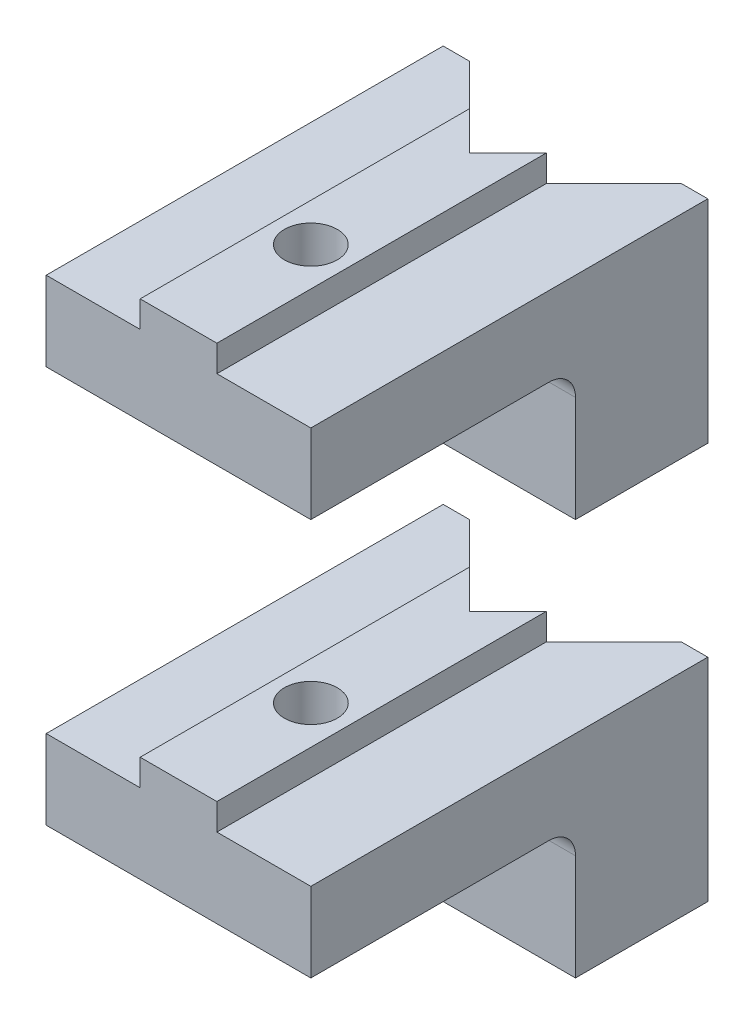
from build123d import *

# Parameters (mm, degrees)
MAIN_DEPTH          = 15
ESQUISSE2_R         = 1
TOPHOLE_DEPTH       = 17.30950643
CUT_EXTRUDE1_DEPTH  = 17.30950643
BOSS_EXTRUDE1_DEPTH = 5
FILLET1_R           = 1
LPATTERN1_COUNT     = 2
LPATTERN1_PITCH     = 15


with BuildPart() as part:
    # Esquisse1 → Main (new body)
    with BuildSketch(Plane.XY):
        Polygon((-5, 0), (-5, 3), (-1.45, 3), (-1.45, 4), (1.45, 4), (1.45, 3), (5, 3), (5, 0), align=None)
    extrude(amount=MAIN_DEPTH)

    # Esquisse2 → TopHole (cut, through all)
    with BuildSketch(Plane(origin=(0, 4, 0), x_dir=(1, 0, 0), z_dir=(0, 1, 0))):
        with Locations((0, -10)):
            Circle(ESQUISSE2_R)
    extrude(amount=-TOPHOLE_DEPTH, mode=Mode.SUBTRACT)

    # Sketch1 → Cut-Extrude1 (cut, through all)
    with BuildSketch(Plane(origin=(0, 0, 0), x_dir=(-1, 0, 0), z_dir=(0, -1, 0))):
        Polygon((5, 1), (0, -4), (-5, 1), align=None)
    extrude(amount=-CUT_EXTRUDE1_DEPTH, mode=Mode.SUBTRACT)

    # Sketch2 → Boss-Extrude1 (add)
    with BuildSketch(Plane(origin=(0, 0, 0), x_dir=(-1, 0, 0), z_dir=(0, -1, 0))):
        Polygon((-5, 0), (-5, -5), (5, -5), (5, 0), (4, 0), (0, -4), (-4, 0), align=None)
    extrude(amount=BOSS_EXTRUDE1_DEPTH)

    # Fillet1
    fillet1_edges = [part.edges().sort_by_distance(p)[0] for p in [
        (0, 0, 5),
    ]]
    fillet(fillet1_edges, radius=FILLET1_R)


with BuildPart() as lpattern1_1:
    # LPattern1: pattern copy
    add(part.part.moved(Location(Vector(0, 1, 0) * (1 * LPATTERN1_PITCH))))


solid = Compound([part.part, lpattern1_1.part])
